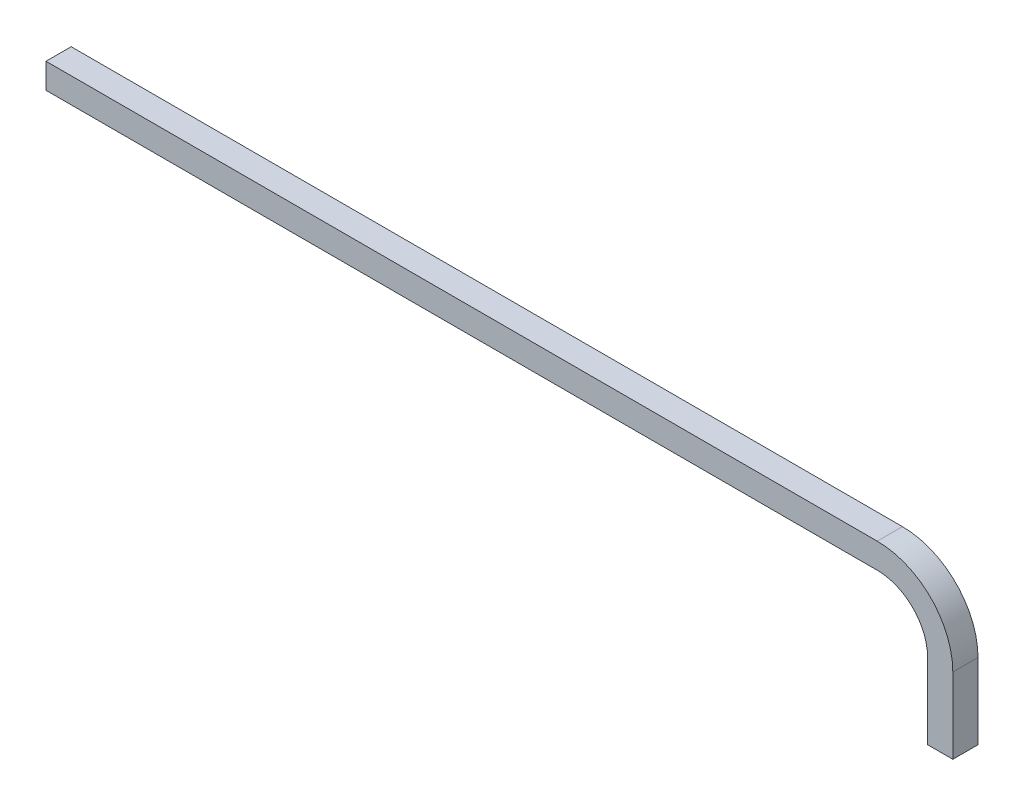
from build123d import *

# Parameters (mm, degrees)
EXTRUDE_1_DEPTH = 25
SHELL_1_T       = -2.2


with BuildPart() as part:
    # Эскиз1 → Бобышка-Вытянуть1 (new body)
    with BuildSketch(Plane.XY):
        with BuildLine():
            Line((-503.628105098, 213.614457831), (321.371894902, 213.614457831))
            ThreePointArc((321.371894902, 213.614457831), (356.727233962, 198.969796891), (371.371894902, 163.614457831))
            Line((371.371894902, 163.614457831), (371.371894902, 88.614457831))
            Line((371.371894902, 88.614457831), (396.371894902, 88.614457831))
            Line((396.371894902, 88.614457831), (396.371894902, 163.614457831))
            ThreePointArc((396.371894902, 163.614457831), (374.404903491, 216.64746642), (321.371894902, 238.614457831))
            Line((321.371894902, 238.614457831), (-503.628105098, 238.614457831))
            Line((-503.628105098, 238.614457831), (-503.628105098, 213.614457831))
        make_face()
    extrude(amount=EXTRUDE_1_DEPTH)

    # Оболочка1
    shell_1_openings = [part.faces().sort_by_distance(p)[0] for p in [
        (383.871894902, 88.614457831, 12.5),
        (-503.628105098, 226.114457831, 12.5),
    ]]
    offset(amount=SHELL_1_T, openings=shell_1_openings, kind=Kind.INTERSECTION)


solid = part.part
